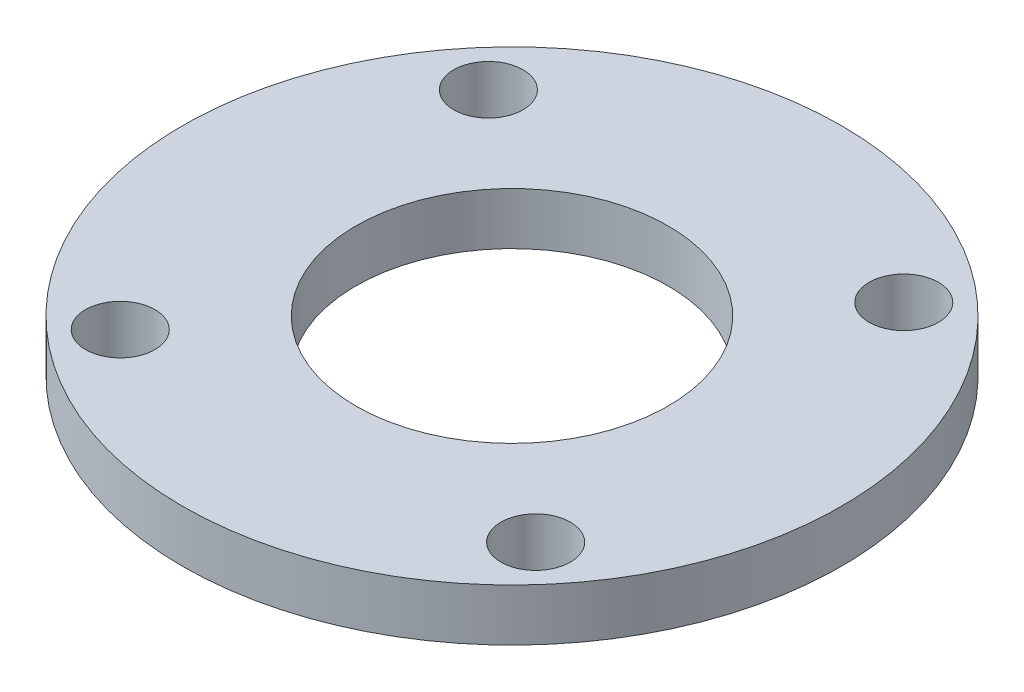
from build123d import *

# Parameters (mm, degrees)
SKETCH1_R           = 19
BOSS_EXTRUDE1_DEPTH = 3
SKETCH2_R           = 2
CUT_EXTRUDE1_DEPTH  = 3
SKETCH3_R           = 9
CUT_EXTRUDE2_DEPTH  = 3


with BuildPart() as part:
    # Sketch1 → Boss-Extrude1 (new body)
    with BuildSketch(Plane(origin=(0, 0, 0), x_dir=(1, 0, 0), z_dir=(0, 1, 0))):
        Circle(SKETCH1_R)
    extrude(amount=BOSS_EXTRUDE1_DEPTH)

    # Sketch2 → Cut-Extrude1 (cut)
    with BuildSketch(Plane(origin=(0, 3, 0), x_dir=(1, 0, 0), z_dir=(0, 1, 0))):
        with Locations((-11.974482975, 10.611868708)):
            Circle(SKETCH2_R)
        with Locations((10.611868708, 11.974482975)):
            Circle(SKETCH2_R)
        with Locations((11.974482975, -10.611868708)):
            Circle(SKETCH2_R)
        with Locations((-10.611868708, -11.974482975)):
            Circle(SKETCH2_R)
    extrude(amount=-CUT_EXTRUDE1_DEPTH, mode=Mode.SUBTRACT)

    # Sketch3 → Cut-Extrude2 (cut)
    with BuildSketch(Plane(origin=(0, 3, 0), x_dir=(1, 0, 0), z_dir=(0, 1, 0))):
        Circle(SKETCH3_R)
    extrude(amount=-CUT_EXTRUDE2_DEPTH, mode=Mode.SUBTRACT)


solid = part.part
